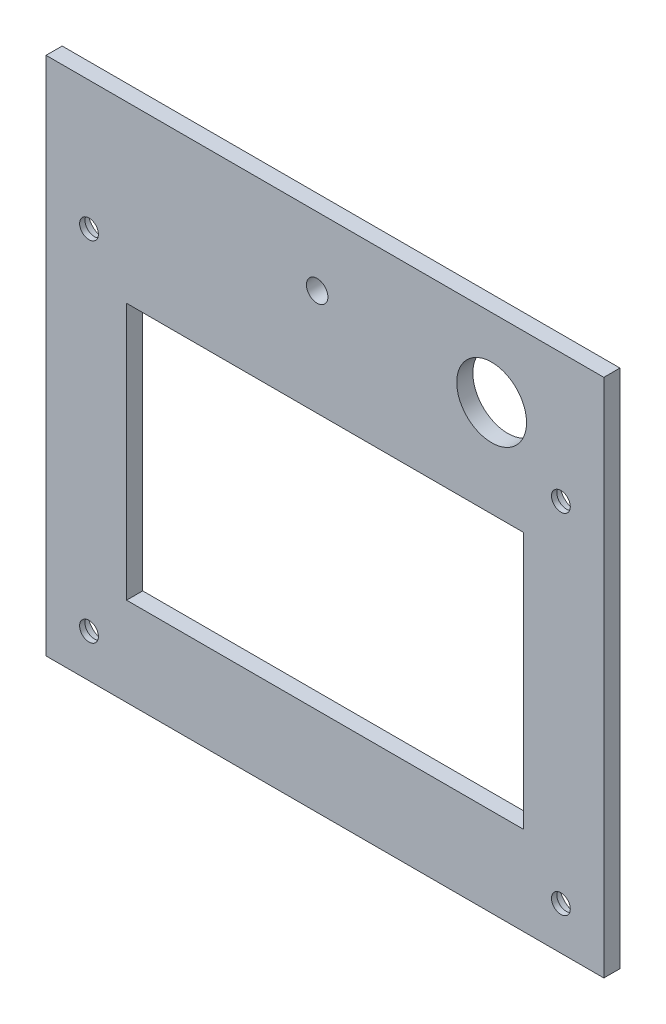
from build123d import *

# Parameters (mm, degrees)
SKETCH1_R           = 1.75
SKETCH1_R_2         = 6.5
SKETCH1_R_3         = 2
SKETCH1_W           = 77.9
SKETCH1_H           = 47.9
BOSS_EXTRUDE1_DEPTH = 3
SKETCH2_W           = 2
SKETCH2_H           = 47.9
BOSS_EXTRUDE2_DEPTH = 3
SKETCH4_W           = 15
SKETCH4_H           = 92.738679811
BOSS_EXTRUDE4_DEPTH = 3
SKETCH5_W           = 15
SKETCH5_H           = 92.013865939
BOSS_EXTRUDE5_DEPTH = 3
SKETCH7_W           = 103.9
SKETCH7_H           = 15
BOSS_EXTRUDE6_DEPTH = 3
SKETCH9_R           = 3.25
CUT_EXTRUDE1_DEPTH  = 2
SKETCH10_W          = 103.9
SKETCH10_H          = 15
BOSS_EXTRUDE8_DEPTH = 3
SKETCH12_R          = 3.75
SKETCH12_R_2        = 1.75
BOSS_EXTRUDE9_DEPTH = 8
SKETCH13_W          = 3
SKETCH13_H          = 23
CUT_EXTRUDE2_DEPTH  = 8
SKETCH14_W          = 281.555590783
SKETCH14_H          = 173.736843818
CUT_EXTRUDE3_DEPTH  = 12


with BuildPart() as part:
    # Sketch1 → Boss-Extrude1 (new body)
    with BuildSketch(Plane.XY):
        Polygon((-5, -5), (-5, 69.9), (-5, 85.9), (92.9, 85.9), (92.9, 69.9), (92.9, -5), align=None)
        with Locations((0, 64.9)):
            Circle(SKETCH1_R, mode=Mode.SUBTRACT)
        with Locations((87.9, 64.9)):
            Circle(SKETCH1_R, mode=Mode.SUBTRACT)
        with Locations((87.9, 0)):
            Circle(SKETCH1_R, mode=Mode.SUBTRACT)
        Circle(SKETCH1_R, mode=Mode.SUBTRACT)
        with Locations((75, 74.4)):
            Circle(SKETCH1_R_2, mode=Mode.SUBTRACT)
        with Locations((42.5, 76.15)):
            Circle(SKETCH1_R_3, mode=Mode.SUBTRACT)
        with Locations((43.95, 32.45)):
            Rectangle(SKETCH1_W, SKETCH1_H, mode=Mode.SUBTRACT)
    extrude(amount=BOSS_EXTRUDE1_DEPTH)

    # Sketch2 → Boss-Extrude2 (add)
    with BuildSketch(Plane.XY.offset(3)):
        with Locations((81.9, 32.45)):
            Rectangle(SKETCH2_W, SKETCH2_H)
        with Locations((6, 32.45)):
            Rectangle(SKETCH2_W, SKETCH2_H)
    extrude(amount=-BOSS_EXTRUDE2_DEPTH)

    # Sketch4 → Boss-Extrude4 (add)
    with BuildSketch(Plane(origin=(92.9, 0, 0), x_dir=(0, 0, -1), z_dir=(1, 0, 0))):
        with Locations((-7.5, 41.369339906)):
            Rectangle(SKETCH4_W, SKETCH4_H)
    extrude(amount=BOSS_EXTRUDE4_DEPTH)

    # Sketch5 → Boss-Extrude5 (add)
    with BuildSketch(Plane.ZY.offset(5)):
        with Locations((7.5, 41.006932969)):
            Rectangle(SKETCH5_W, SKETCH5_H)
    extrude(amount=BOSS_EXTRUDE5_DEPTH)

    # Sketch7 → Boss-Extrude6 (add)
    with BuildSketch(Plane(origin=(0, -5, 0), x_dir=(-1, 0, 0), z_dir=(0, -1, 0))):
        with Locations((-43.95, -7.5)):
            Rectangle(SKETCH7_W, SKETCH7_H)
    extrude(amount=BOSS_EXTRUDE6_DEPTH)

    # Sketch9 → Cut-Extrude1 (cut)
    with BuildSketch(Plane(origin=(0, 0, 0), x_dir=(-1, 0, 0), z_dir=(0, 0, -1))):
        Circle(SKETCH9_R)
        with Locations((-87.9, 0)):
            Circle(SKETCH9_R)
        with Locations((-87.9, 64.9)):
            Circle(SKETCH9_R)
        with Locations((0, 64.9)):
            Circle(SKETCH9_R)
    extrude(amount=-CUT_EXTRUDE1_DEPTH, mode=Mode.SUBTRACT)

    # Sketch10 → Boss-Extrude8 (add)
    with BuildSketch(Plane(origin=(0, 85.9, 0), x_dir=(1, 0, 0), z_dir=(0, 1, 0))):
        with Locations((43.95, -7.5)):
            Rectangle(SKETCH10_W, SKETCH10_H)
    extrude(amount=BOSS_EXTRUDE8_DEPTH)

    # Sketch12 → Boss-Extrude9 (add)
    with BuildSketch(Plane.XY.offset(3)):
        with Locations((0, 64.9)):
            Circle(SKETCH12_R)
        with Locations((0, 64.9)):
            Circle(SKETCH12_R_2, mode=Mode.SUBTRACT)
        Circle(SKETCH12_R)
        Circle(SKETCH12_R_2, mode=Mode.SUBTRACT)
        with Locations((87.9, 64.9)):
            Circle(SKETCH12_R)
        with Locations((87.9, 64.9)):
            Circle(SKETCH12_R_2, mode=Mode.SUBTRACT)
        with Locations((87.9, 0)):
            Circle(SKETCH12_R)
        with Locations((87.9, 0)):
            Circle(SKETCH12_R_2, mode=Mode.SUBTRACT)
    extrude(amount=BOSS_EXTRUDE9_DEPTH)

    # Sketch13 → Cut-Extrude2 (cut)
    with BuildSketch(Plane(origin=(95.9, 0, 0), x_dir=(0, 0, -1), z_dir=(1, 0, 0))):
        with Locations((-13.5, 53.54685285)):
            Rectangle(SKETCH13_W, SKETCH13_H)
    extrude(amount=-CUT_EXTRUDE2_DEPTH, mode=Mode.SUBTRACT)

    # Sketch14 → Cut-Extrude3 (cut)
    with BuildSketch(Plane.XY.offset(15)):
        with Locations((95.022411609, 36.684941712)):
            Rectangle(SKETCH14_W, SKETCH14_H)
    extrude(amount=-CUT_EXTRUDE3_DEPTH, mode=Mode.SUBTRACT)


solid = part.part
